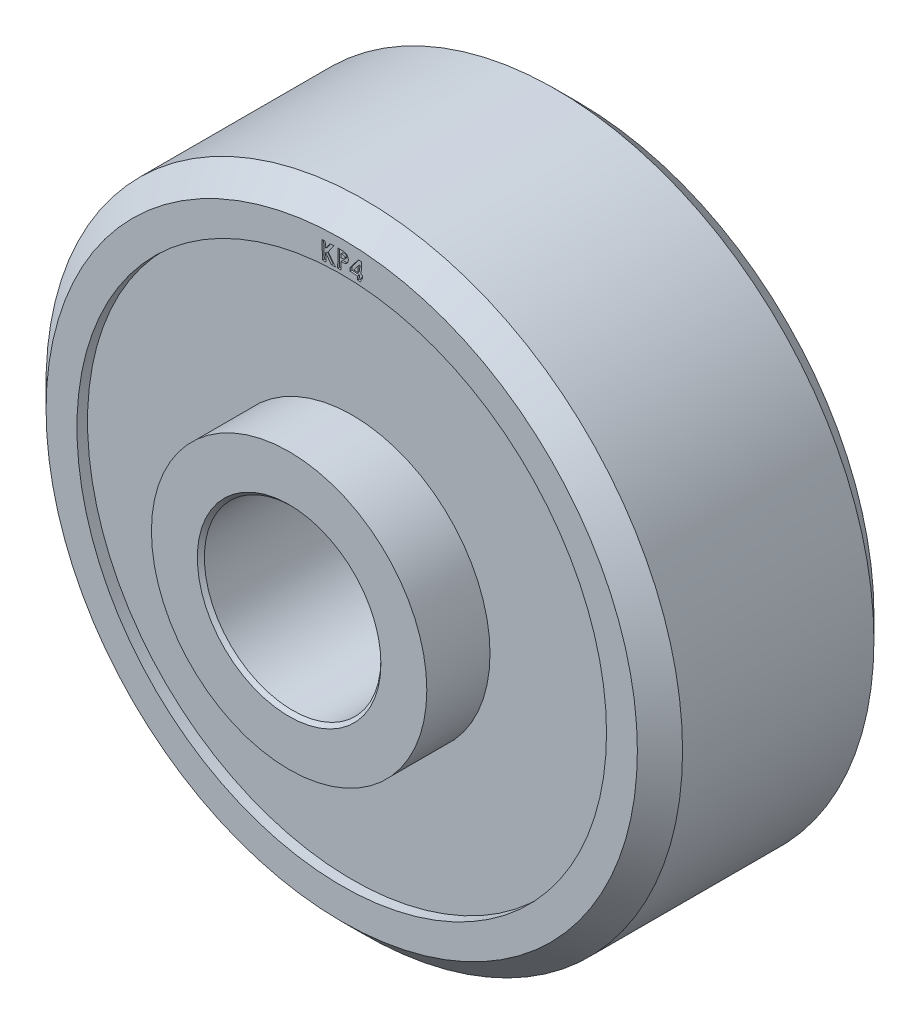
from build123d import *

# Parameters (mm, degrees)
CUT_EXTRUDE1_DEPTH = 0.0635


with BuildPart() as part:
    # Sketch1 → Revolve1 (revolve)
    with BuildSketch(Plane(origin=(0, 0, 0), x_dir=(0, 0, -1), z_dir=(1, 0, 0))):
        Polygon((-6.1468, 3.302), (-6.1468, 4.953), (-3.8735, 4.953), (-3.8735, 9.525), (-4.2545, 9.525), (-4.2545, 10.63498), (-3.4417, 11.44778), (3.4417, 11.44778), (4.2545, 10.63498), (4.2545, 9.525), (3.8735, 9.525), (3.8735, 4.953), (6.1468, 4.953), (6.1468, 3.302), (6.0198, 3.175), (-6.0198, 3.175), align=None)
    revolve(axis=Axis((0, 0, 0), (0, 0, -1)))

    # Sketch2 → Cut-Extrude1 (cut)
    with BuildSketch(Plane.XY.offset(4.2545)):
        Polygon((-0.715797037, 10.256682265), (-0.59431767, 10.262024813), (-0.584777405, 10.044761191), (-0.422974521, 10.269529821), (-0.278344112, 10.275889997), (-0.486703487, 9.984593924), (-0.229243551, 9.645214917), (-0.371838703, 9.638981945), (-0.578926043, 9.910815879), (-0.566714505, 9.630459308), (-0.688193872, 9.62511676), align=None)
        with BuildLine():
            Line((-0.137056778, 10.280248194), (-0.009598846, 10.278721752))
            add(Edge.make_bspline(
                [(-0.009598846, 10.278721752), (-0.001287185, 10.278547688), (0.014749364, 10.278211849), (0.03791593, 10.277113779), (0.059251361, 10.275324059), (0.078823772, 10.273084067), (0.09658198, 10.270220031), (0.112510114, 10.266682791), (0.126614201, 10.262601864), (0.139181226, 10.258063486), (0.150404482, 10.252540227), (0.160921964, 10.246543676), (0.170857479, 10.23986336), (0.180015832, 10.232238122), (0.18873639, 10.22412794), (0.196758904, 10.215173588), (0.20416167, 10.205477286), (0.210872704, 10.195028329), (0.216953317, 10.184045094), (0.222263409, 10.172503694), (0.226470626, 10.160357095), (0.230295983, 10.147804967), (0.232853006, 10.134621192), (0.234815576, 10.120999554), (0.235807514, 10.106842586), (0.235871459, 10.09724597), (0.235903959, 10.092368587)],
                knots=[0, 0, 0, 0, 2.494e-05, 4.8119e-05, 6.9564e-05, 8.916e-05, 0.000107207, 0.000123502, 0.000138074, 0.000151235, 0.000163524, 0.000175547, 0.000187542, 0.000199383, 0.000211261, 0.000223241, 0.000235402, 0.000247822, 0.000260461, 0.000273041, 0.000285876, 0.000298999, 0.00031237, 0.000326114, 0.00034027, 0.000354901, 0.000354901, 0.000354901, 0.000354901], degree=3))
            add(Edge.make_bspline(
                [(0.235903959, 10.092368587), (0.235726012, 10.086978535), (0.235376195, 10.076382465), (0.233555914, 10.06086812), (0.230820019, 10.046045066), (0.226846103, 10.031957239), (0.221762472, 10.018597169), (0.21559979, 10.005933869), (0.208512368, 9.993900042), (0.200177911, 9.982742598), (0.191049434, 9.97230186), (0.181048202, 9.962734678), (0.170368482, 9.953924746), (0.158877942, 9.946006271), (0.146611538, 9.939059919), (0.133705365, 9.932726844), (0.119932481, 9.927410793), (0.110374057, 9.924525718), (0.105520345, 9.923060694)],
                knots=[0, 0, 0, 0, 1.6173e-05, 3.1794e-05, 4.6812e-05, 6.135e-05, 7.5642e-05, 8.9638e-05, 0.000103556, 0.000117472, 0.000131353, 0.000145118, 0.000158945, 0.000172847, 0.000186921, 0.000201201, 0.000215941, 0.000231148, 0.000231148, 0.000231148, 0.000231148], degree=3))
            add(Edge.make_bspline(
                [(0.105520345, 9.923060694), (0.102347959, 9.922302526), (0.09541168, 9.920644826), (0.084019105, 9.918830767), (0.070821383, 9.917299868), (0.055878254, 9.91624699), (0.039130219, 9.915304899), (0.020635268, 9.914885629), (0.000323735, 9.914573099), (-0.013796465, 9.914717181), (-0.021174367, 9.914792465)],
                knots=[0, 0, 0, 0, 9.782e-06, 2.1389e-05, 3.4579e-05, 4.9633e-05, 6.632e-05, 8.4899e-05, 0.000105126, 0.00012726, 0.00012726, 0.00012726, 0.00012726], degree=3))
            Line((-0.021174367, 9.914792465), (-0.024481658, 9.647283451))
            Line((-0.024481658, 9.647283451), (-0.14468899, 9.648682689))
            Line((-0.14468899, 9.648682689), (-0.137056778, 10.280248194))
        make_face()
        with BuildLine():
            Line((-0.019775128, 10.031946912), (0.01838593, 10.031438098))
            add(Edge.make_bspline(
                [(0.01838593, 10.031438098), (0.025341366, 10.031399241), (0.038074588, 10.031328107), (0.055487961, 10.032349425), (0.06951657, 10.033931542), (0.080657527, 10.0365482), (0.089494488, 10.040499929), (0.097092732, 10.045183773), (0.103672216, 10.051029279), (0.109309451, 10.057830338), (0.113976457, 10.065587683), (0.117032077, 10.074351893), (0.119207899, 10.083784291), (0.119492561, 10.090362271), (0.119639936, 10.093767826)],
                knots=[0, 0, 0, 0, 2.0862e-05, 3.8191e-05, 5.2297e-05, 6.3187e-05, 7.2357e-05, 8.1216e-05, 8.9868e-05, 9.863e-05, 0.00010764, 0.000116856, 0.000126362, 0.000136567, 0.000136567, 0.000136567, 0.000136567], degree=3))
            add(Edge.make_bspline(
                [(0.119639936, 10.093767826), (0.119562982, 10.096695704), (0.119412912, 10.102405414), (0.118359789, 10.110681571), (0.116121516, 10.118318497), (0.113057229, 10.125379216), (0.109137816, 10.131858318), (0.104301671, 10.13772663), (0.09857412, 10.142976641), (0.094159169, 10.145854249), (0.091909568, 10.14732051)],
                knots=[0, 0, 0, 0, 8.785e-06, 1.7132e-05, 2.4943e-05, 3.2576e-05, 4.0168e-05, 4.7579e-05, 5.5322e-05, 6.3367e-05, 6.3367e-05, 6.3367e-05, 6.3367e-05], degree=3))
            add(Edge.make_bspline(
                [(0.091909568, 10.14732051), (0.090027961, 10.148394937), (0.086056367, 10.150662781), (0.07913742, 10.153076263), (0.071314393, 10.15542692), (0.062261301, 10.157108271), (0.052170636, 10.158639954), (0.040923672, 10.159801584), (0.028609183, 10.160347889), (0.020039846, 10.160564391), (0.015587452, 10.16067688)],
                knots=[0, 0, 0, 0, 6.487e-06, 1.3693e-05, 2.1905e-05, 3.0986e-05, 4.1276e-05, 5.2528e-05, 6.4884e-05, 7.8245e-05, 7.8245e-05, 7.8245e-05, 7.8245e-05], degree=3))
            Line((0.015587452, 10.16067688), (-0.018248685, 10.161185694))
            Line((-0.018248685, 10.161185694), (-0.019775128, 10.031946912))
        make_face(mode=Mode.SUBTRACT)
        Polygon((0.598009372, 10.279863333), (0.718216704, 10.273375953), (0.696210494, 9.866706281), (0.752434453, 9.863653397), (0.746328683, 9.752477515), (0.690104725, 9.7555304), (0.683108531, 9.625910007), (0.565572473, 9.632270184), (0.572568667, 9.761890576), (0.296918627, 9.776773389), (0.303024397, 9.88794927), align=None)
        Polygon((0.578674437, 9.873066458), (0.590122754, 10.084733124), (0.434425638, 9.880825873), align=None, mode=Mode.SUBTRACT)
    extrude(amount=-CUT_EXTRUDE1_DEPTH, mode=Mode.SUBTRACT)


solid = part.part
